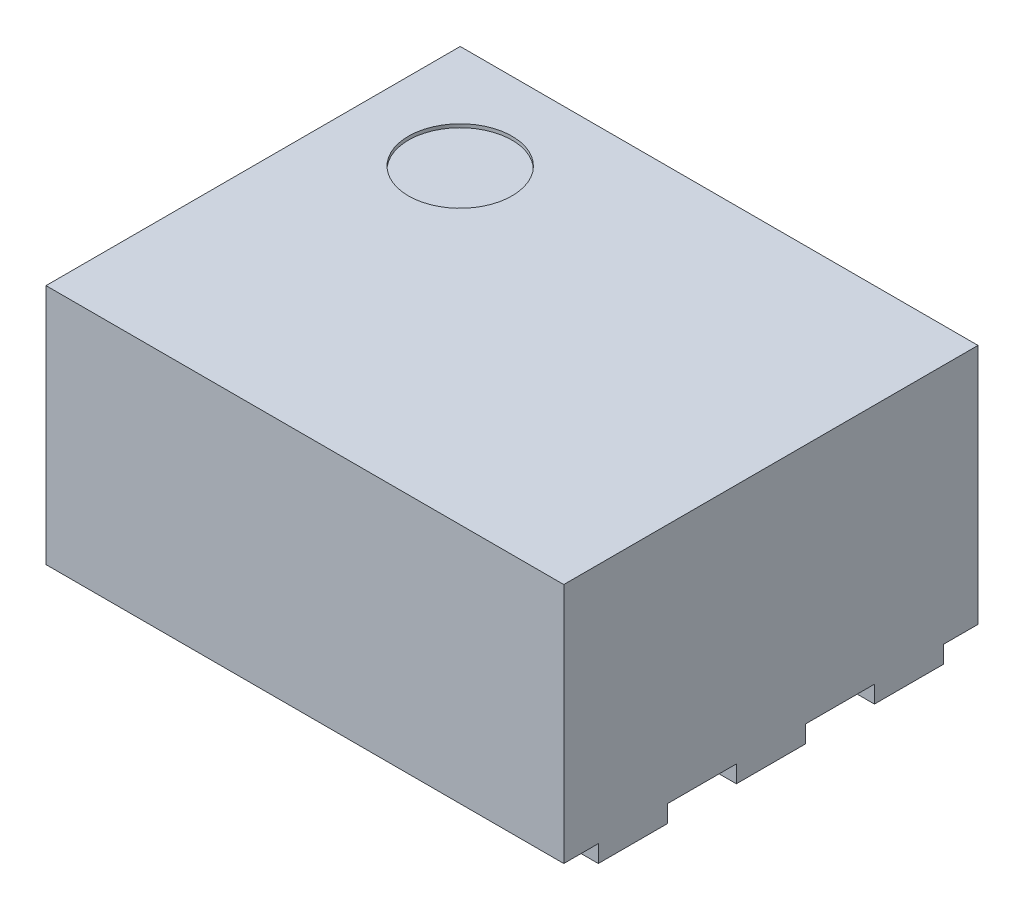
from build123d import *

# Parameters (mm, degrees)
SKETCH1_W           = 1.5
SKETCH1_H           = 1.2
BOSS_EXTRUDE1_DEPTH = 0.7
SKETCH2_W           = 0.29
SKETCH2_H           = 0.2
SKETCH2_W_2         = 0.47
SKETCH2_H_2         = 0.85
BOSS_EXTRUDE2_DEPTH = 0.05
SKETCH3_R           = 0.15
CUT_EXTRUDE1_DEPTH  = 0.01


with BuildPart() as part:
    # Sketch1 → Boss-Extrude1 (new body)
    with BuildSketch(Plane(origin=(0, 0, 0), x_dir=(1, 0, 0), z_dir=(0, 1, 0))):
        Rectangle(SKETCH1_W, SKETCH1_H)
    extrude(amount=BOSS_EXTRUDE1_DEPTH)

    # Sketch2 → Boss-Extrude2 (add)
    with BuildSketch(Plane.XZ):
        with Locations((-0.605, 0.4)):
            Rectangle(SKETCH2_W, SKETCH2_H)
        Rectangle(SKETCH2_W_2, SKETCH2_H_2)
        with Locations((-0.605, -0.4)):
            Rectangle(SKETCH2_W, SKETCH2_H)
        with Locations((-0.605, 0)):
            Rectangle(SKETCH2_W, SKETCH2_H)
        with Locations((0.605, -0.4)):
            Rectangle(SKETCH2_W, SKETCH2_H)
        with Locations((0.605, 0)):
            Rectangle(SKETCH2_W, SKETCH2_H)
        with Locations((0.605, 0.4)):
            Rectangle(SKETCH2_W, SKETCH2_H)
    extrude(amount=BOSS_EXTRUDE2_DEPTH)

    # Sketch3 → Cut-Extrude1 (cut)
    with BuildSketch(Plane(origin=(0, 0.7, 0), x_dir=(1, 0, 0), z_dir=(0, 1, 0))):
        with Locations((-0.45, 0.3)):
            Circle(SKETCH3_R)
    extrude(amount=-CUT_EXTRUDE1_DEPTH, mode=Mode.SUBTRACT)


solid = part.part
